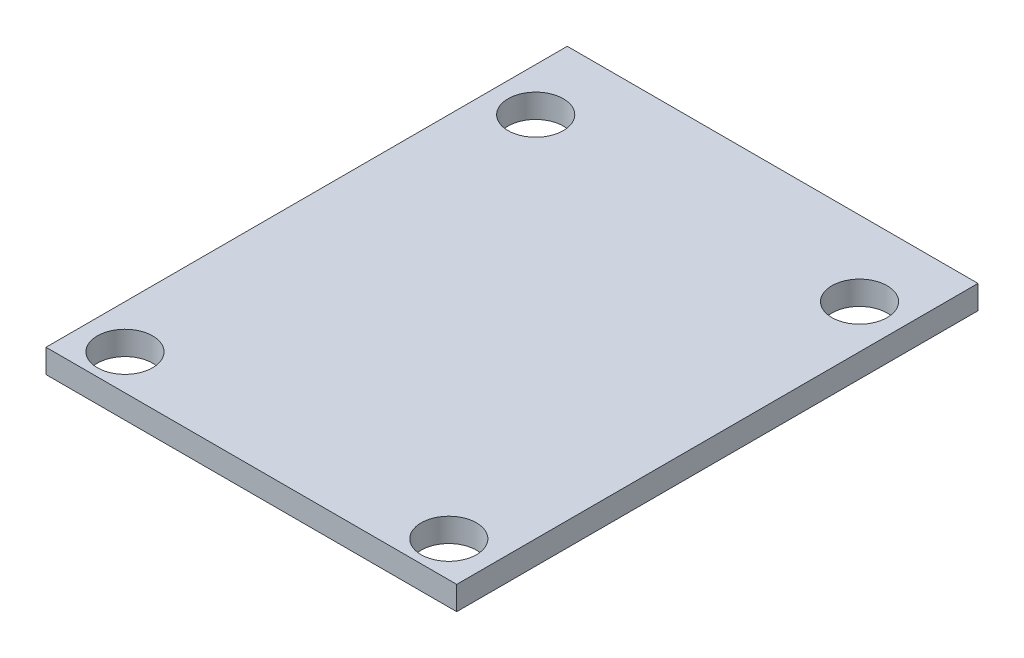
from build123d import *

# Parameters (mm, degrees)
SKETCH1_W           = 26
SKETCH1_H           = 33
SKETCH1_R           = 1.75
BOSS_EXTRUDE1_DEPTH = 1.5


with BuildPart() as part:
    # Sketch1 → Boss-Extrude1 (new body)
    with BuildSketch(Plane(origin=(0, 0, 0), x_dir=(1, 0, 0), z_dir=(0, 1, 0))):
        Rectangle(SKETCH1_W, SKETCH1_H)
        with Locations((10.25, -14.25)):
            Circle(SKETCH1_R, mode=Mode.SUBTRACT)
        with Locations((-10.25, -14.25)):
            Circle(SKETCH1_R, mode=Mode.SUBTRACT)
        with Locations((10.25, 11.75)):
            Circle(SKETCH1_R, mode=Mode.SUBTRACT)
        with Locations((-10.25, 11.75)):
            Circle(SKETCH1_R, mode=Mode.SUBTRACT)
    extrude(amount=BOSS_EXTRUDE1_DEPTH)


solid = part.part
